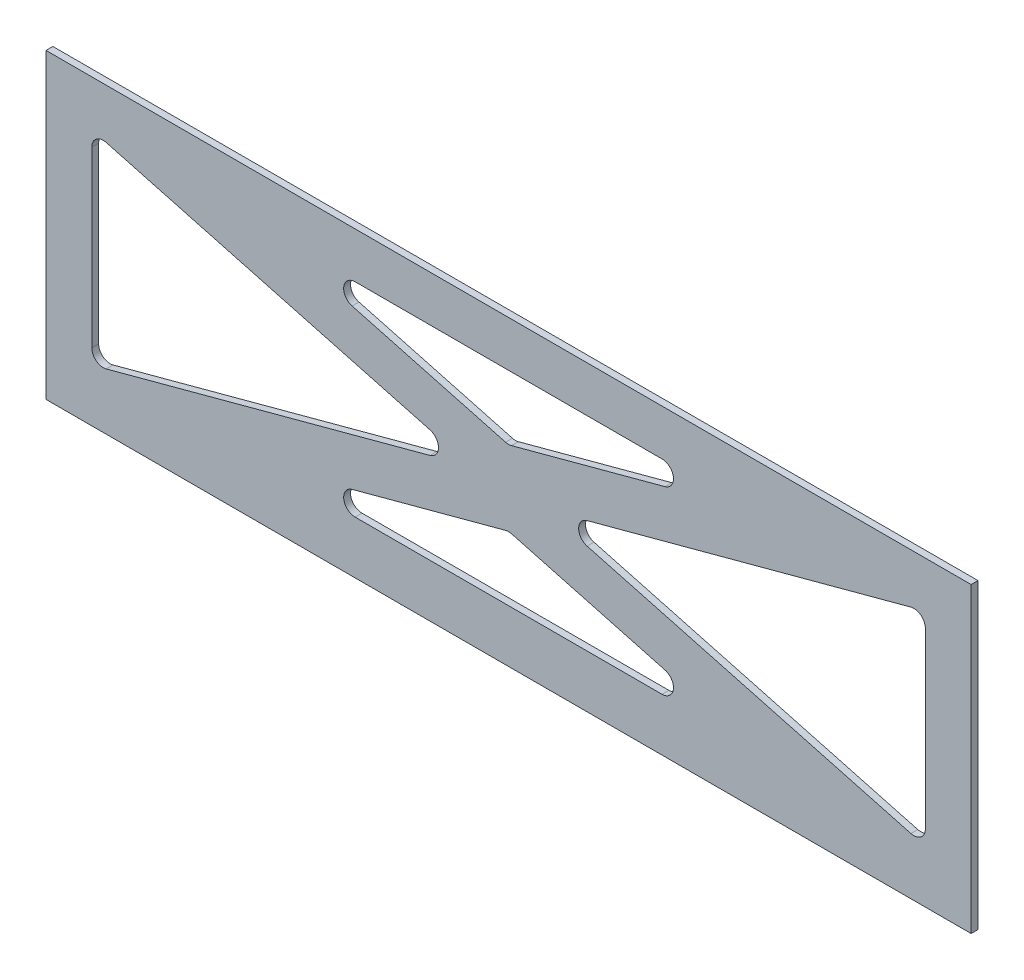
from build123d import *

# Parameters (mm, degrees)
SKETCH1_W           = 404
SKETCH1_H           = 132
BOSS_EXTRUDE1_DEPTH = 3


with BuildPart() as part:
    # Sketch1 → Boss-Extrude1 (new body)
    with BuildSketch(Plane.XY.offset(152)):
        with Locations((85.526581968, -69.40919868)):
            Rectangle(SKETCH1_W, SKETCH1_H)
        with BuildLine():
            Line((-96.473418032, -105.888993971), (-96.473418032, -29.929403389))
            ThreePointArc((-96.473418032, -29.929403389), (-94.516026587, -25.961717264), (-90.176404758, -25.100557091))
            Line((-90.176404758, -25.100557091), (51.22430223, -63.080352382))
            ThreePointArc((51.22430223, -63.080352382), (54.927288957, -67.90919868), (51.22430223, -72.738044978))
            Line((51.22430223, -72.738044978), (-90.176404758, -110.717840269))
            ThreePointArc((-90.176404758, -110.717840269), (-94.516026587, -109.856680096), (-96.473418032, -105.888993971))
        make_face(mode=Mode.SUBTRACT)
        with BuildLine():
            Line((152.536061434, -23.40919868), (18.517102502, -23.40919868))
            ThreePointArc((18.517102502, -23.40919868), (13.560075596, -27.755070057), (17.220089228, -33.238044978))
            Line((17.220089228, -33.238044978), (84.229568694, -51.236585203))
            ThreePointArc((84.229568694, -51.236585203), (85.526581968, -51.407738905), (86.823595242, -51.236585203))
            Line((86.823595242, -51.236585203), (153.833074707, -33.238044978))
            ThreePointArc((153.833074707, -33.238044978), (157.493088339, -27.755070057), (152.536061434, -23.40919868))
        make_face(mode=Mode.SUBTRACT)
        with BuildLine():
            Line((261.229568694, -25.100557091), (119.828861705, -63.080352382))
            ThreePointArc((119.828861705, -63.080352382), (116.125874979, -67.90919868), (119.828861705, -72.738044978))
            Line((119.828861705, -72.738044978), (261.229568694, -110.717840269))
            ThreePointArc((261.229568694, -110.717840269), (265.569190522, -109.856680096), (267.526581968, -105.888993971))
            Line((267.526581968, -105.888993971), (267.526581968, -29.929403389))
            ThreePointArc((267.526581968, -29.929403389), (265.569190522, -25.961717264), (261.229568694, -25.100557091))
        make_face(mode=Mode.SUBTRACT)
        with BuildLine():
            Line((17.220089228, -102.580352382), (84.229568694, -84.581812156))
            ThreePointArc((84.229568694, -84.581812156), (85.526581968, -84.410658454), (86.823595242, -84.581812156))
            Line((86.823595242, -84.581812156), (153.833074707, -102.580352382))
            ThreePointArc((153.833074707, -102.580352382), (157.493088339, -108.063327303), (152.536061434, -112.40919868))
            Line((152.536061434, -112.40919868), (18.517102502, -112.40919868))
            ThreePointArc((18.517102502, -112.40919868), (13.560075596, -108.063327303), (17.220089228, -102.580352382))
        make_face(mode=Mode.SUBTRACT)
    extrude(amount=BOSS_EXTRUDE1_DEPTH)


solid = part.part
